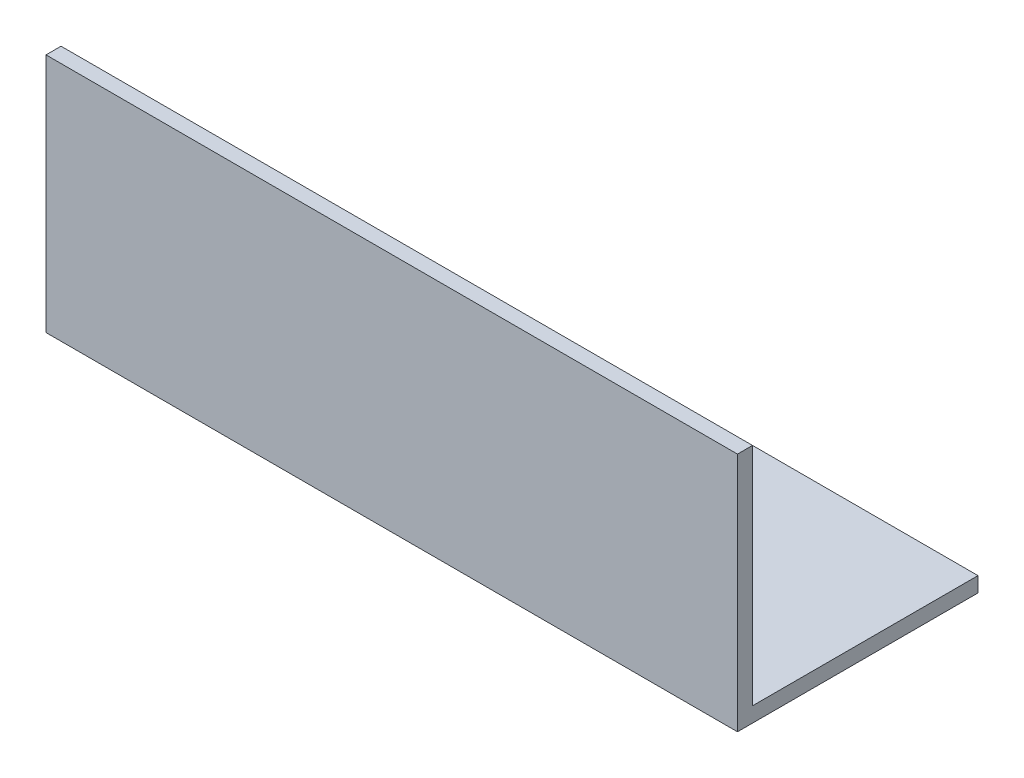
from build123d import *

# Parameters (mm, degrees)
EXTRUDE_1_DEPTH = 230


with BuildPart() as part:
    # Эскиз1 → Вытянуть-Тонкостенный1 (new body)
    with BuildSketch(Plane(origin=(0, 0, 0), x_dir=(0, 0, -1), z_dir=(1, 0, 0))):
        Polygon((75, 0), (0, 0), (0, 75), (-5, 75), (-5, -5), (75, -5), align=None)
    extrude(amount=EXTRUDE_1_DEPTH)


solid = part.part
